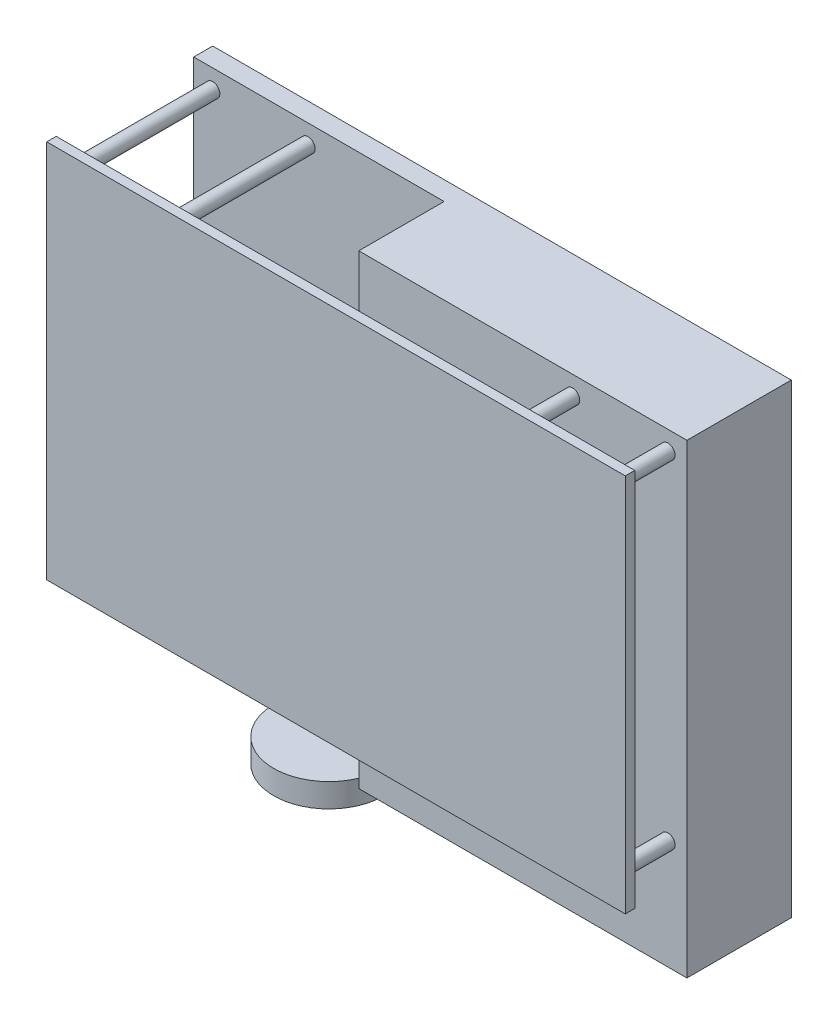
from build123d import *

# Parameters (mm, degrees)
SKETCH_1_W      = 122
SKETCH_1_H      = 80
EXTRUDE_1_DEPTH = 2
SKETCH_2_R      = 1.5
EXTRUDE_3_DEPTH = 31
SKETCH_5_W      = 122
SKETCH_5_H      = 98.2
EXTRUDE_5_DEPTH = 4
SKETCH_6_W      = 69.2
SKETCH_6_H      = 98.2
EXTRUDE_6_DEPTH = 18
SKETCH_7_R      = 11.65
EXTRUDE_9_DEPTH = 5


with BuildPart() as part:
    # 草图1 → 凸台-拉伸1 (new body)
    with BuildSketch(Plane.XY):
        Rectangle(SKETCH_1_W, SKETCH_1_H)
    extrude(amount=EXTRUDE_1_DEPTH)

    # 草图2 → 凸台-拉伸3 (add)
    with BuildSketch(Plane.XY.offset(2)):
        with Locations((-36.9, 36)):
            Circle(SKETCH_2_R)
        with Locations((57, 36)):
            Circle(SKETCH_2_R)
        with Locations((-11.5, -35.2)):
            Circle(SKETCH_2_R)
        with Locations((57, -35.2)):
            Circle(SKETCH_2_R)
    extrude_3 = extrude(amount=-EXTRUDE_3_DEPTH)

    # 草图5 → 凸台-拉伸5 (add)
    with BuildSketch(Plane(origin=(0, 0, -29), x_dir=(-1, 0, 0), z_dir=(0, 0, -1))):
        with Locations((0, -9.1)):
            Rectangle(SKETCH_5_W, SKETCH_5_H)
    extrude(amount=EXTRUDE_5_DEPTH)

    # 镜向2: 凸台-拉伸3 across plane
    add(extrude_3.mirror(Plane(origin=(0, 0, 0), x_dir=(0, 0, 1), z_dir=(1, 0, 0))))

    # 草图6 → 凸台-拉伸6 (add)
    with BuildSketch(Plane.XY.offset(-29)):
        with Locations((26.4, -9.1)):
            Rectangle(SKETCH_6_W, SKETCH_6_H)
    extrude(amount=EXTRUDE_6_DEPTH)


with BuildPart() as body_2:
    # 草图7 → 凸台-拉伸9 (new body)
    with BuildSketch(Plane.XZ.offset(58.2)):
        with Locations((-20.85, -17.35)):
            Circle(SKETCH_7_R)
    extrude(amount=EXTRUDE_9_DEPTH)


solid = Compound([part.part, body_2.part])
